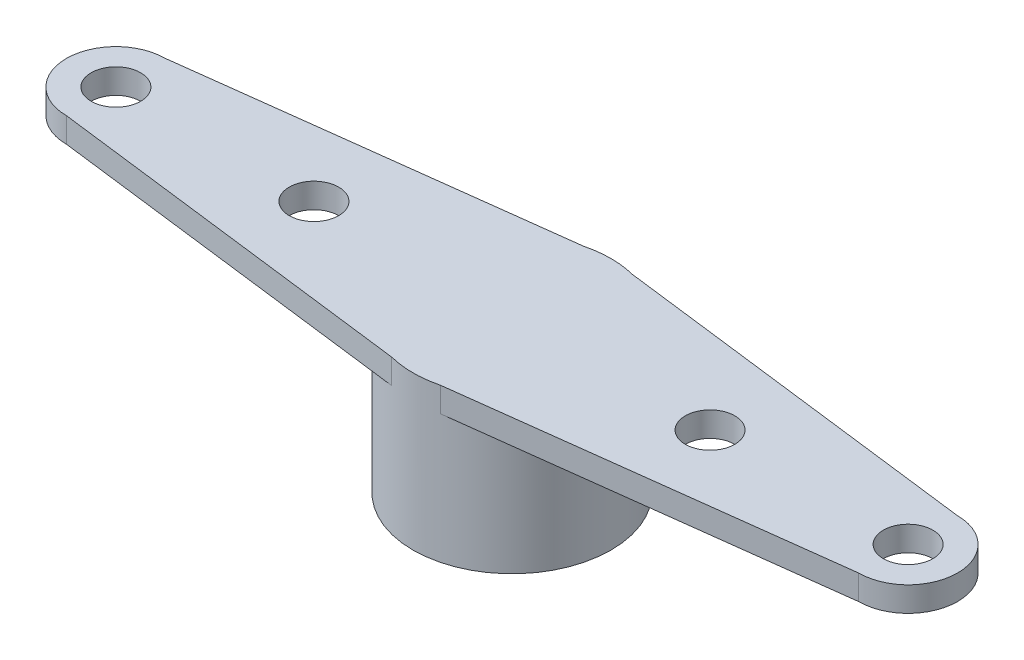
from build123d import *

# Parameters (mm, degrees)
SKETCH2_R           = 0.635
BOSS_EXTRUDE2_DEPTH = 0.635
SKETCH3_R           = 2.54
BOSS_EXTRUDE3_DEPTH = 3.302
SKETCH4_R           = 2.286
CUT_EXTRUDE1_DEPTH  = 3.302


with BuildPart() as part:
    # Sketch2 → Boss-Extrude2 (new body)
    with BuildSketch(Plane(origin=(0, 0, 0), x_dir=(1, 0, 0), z_dir=(0, 1, 0))):
        with BuildLine():
            Line((-10.16, -1.27), (-0.625230769, -2.461846154))
            ThreePointArc((-0.625230769, -2.461846154), (0, -2.54), (0.625230769, -2.461846154))
            Line((0.625230769, -2.461846154), (10.16, -1.27))
            ThreePointArc((10.16, -1.27), (11.43, 0), (10.16, 1.27))
            Line((10.16, 1.27), (0.625230769, 2.461846154))
            ThreePointArc((0.625230769, 2.461846154), (0, 2.54), (-0.625230769, 2.461846154))
            Line((-0.625230769, 2.461846154), (-10.16, 1.27))
            ThreePointArc((-10.16, 1.27), (-11.43, 0), (-10.16, -1.27))
        make_face()
        with Locations((5.08, 0)):
            Circle(SKETCH2_R, mode=Mode.SUBTRACT)
        with Locations((10.16, 0)):
            Circle(SKETCH2_R, mode=Mode.SUBTRACT)
        with Locations((-10.16, 0)):
            Circle(SKETCH2_R, mode=Mode.SUBTRACT)
        with Locations((-5.08, 0)):
            Circle(SKETCH2_R, mode=Mode.SUBTRACT)
    extrude(amount=BOSS_EXTRUDE2_DEPTH)

    # Sketch3 → Boss-Extrude3 (add)
    with BuildSketch(Plane.XZ):
        Circle(SKETCH3_R)
    extrude(amount=BOSS_EXTRUDE3_DEPTH)

    # Sketch4 → Cut-Extrude1 (cut)
    with BuildSketch(Plane(origin=(0, -3.302, 0), x_dir=(-1, 0, 0), z_dir=(0, -1, 0))):
        Circle(SKETCH4_R)
    extrude(amount=-CUT_EXTRUDE1_DEPTH, mode=Mode.SUBTRACT)


solid = part.part
